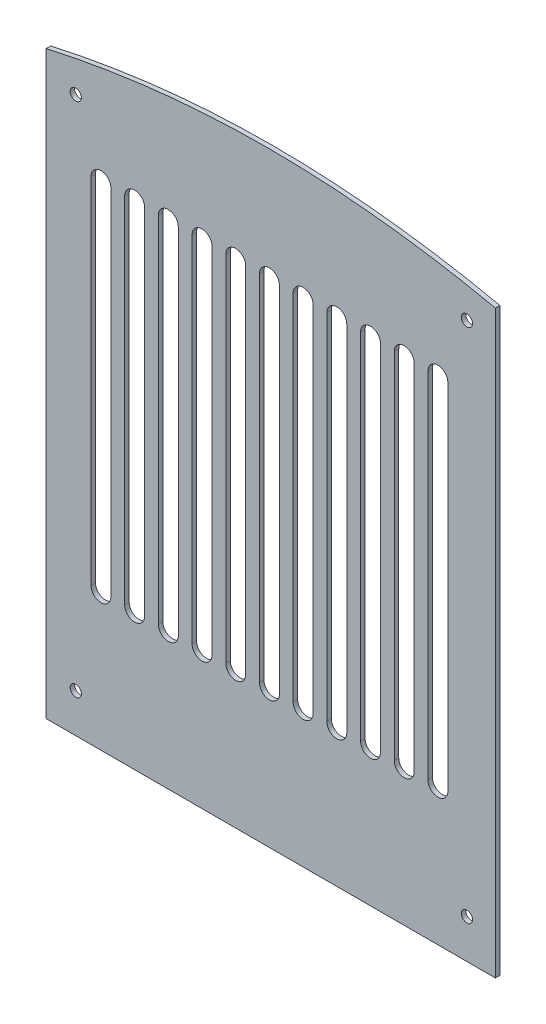
from build123d import *

# Parameters (mm, degrees)
SKETCH1_R           = 2.5
BOSS_EXTRUDE1_DEPTH = 2


with BuildPart() as part:
    # Sketch1 → Boss-Extrude1 (new body)
    with BuildSketch(Plane.XY):
        with BuildLine():
            Line((79.989677419, 0), (-120.010322581, 0))
            Line((-120.010322581, 0), (-120.010322581, 258.3))
            add(Edge.make_bspline(
                [(-120.010322581, 258.3), (-22.49451042, 280.450990468), (79.989677419, 258.3)],
                knots=[0, 0, 0, 1, 1, 1], degree=2))
            Line((79.989677419, 258.3), (79.989677419, 0))
        make_face()
        with Locations((-106.803669914, 247.177426871)):
            Circle(SKETCH1_R, mode=Mode.SUBTRACT)
        with Locations((67.322454172, 247.177426871)):
            Circle(SKETCH1_R, mode=Mode.SUBTRACT)
        with Locations((67.322454172, 17.342199543)):
            Circle(SKETCH1_R, mode=Mode.SUBTRACT)
        with Locations((-106.803669914, 17.342199543)):
            Circle(SKETCH1_R, mode=Mode.SUBTRACT)
        with BuildLine():
            Line((-91.175010368, 219.031134186), (-91.175010368, 61.345209981))
            ThreePointArc((-91.175010368, 61.345209981), (-95.604390261, 56.915830088), (-100.033770154, 61.345209981))
            Line((-100.033770154, 61.345209981), (-100.033770154, 219.031134186))
            ThreePointArc((-100.033770154, 219.031134186), (-95.604390261, 223.460514079), (-91.175010368, 219.031134186))
        make_face(mode=Mode.SUBTRACT)
        with BuildLine():
            Line((-76.175010368, 219.031134186), (-76.175010368, 61.345209981))
            ThreePointArc((-76.175010368, 61.345209981), (-80.604390261, 56.915830088), (-85.033770154, 61.345209981))
            Line((-85.033770154, 61.345209981), (-85.033770154, 219.031134186))
            ThreePointArc((-85.033770154, 219.031134186), (-80.604390261, 223.460514079), (-76.175010368, 219.031134186))
        make_face(mode=Mode.SUBTRACT)
        with BuildLine():
            Line((-61.175010368, 219.031134186), (-61.175010368, 61.345209981))
            ThreePointArc((-61.175010368, 61.345209981), (-65.604390261, 56.915830088), (-70.033770154, 61.345209981))
            Line((-70.033770154, 61.345209981), (-70.033770154, 219.031134186))
            ThreePointArc((-70.033770154, 219.031134186), (-65.604390261, 223.460514079), (-61.175010368, 219.031134186))
        make_face(mode=Mode.SUBTRACT)
        with BuildLine():
            Line((-46.175010368, 219.031134186), (-46.175010368, 61.345209981))
            ThreePointArc((-46.175010368, 61.345209981), (-50.604390261, 56.915830088), (-55.033770154, 61.345209981))
            Line((-55.033770154, 61.345209981), (-55.033770154, 219.031134186))
            ThreePointArc((-55.033770154, 219.031134186), (-50.604390261, 223.460514079), (-46.175010368, 219.031134186))
        make_face(mode=Mode.SUBTRACT)
        with BuildLine():
            Line((-31.175010368, 219.031134186), (-31.175010368, 61.345209981))
            ThreePointArc((-31.175010368, 61.345209981), (-35.604390261, 56.915830088), (-40.033770154, 61.345209981))
            Line((-40.033770154, 61.345209981), (-40.033770154, 219.031134186))
            ThreePointArc((-40.033770154, 219.031134186), (-35.604390261, 223.460514079), (-31.175010368, 219.031134186))
        make_face(mode=Mode.SUBTRACT)
        with BuildLine():
            Line((-16.175010368, 219.031134186), (-16.175010368, 61.345209981))
            ThreePointArc((-16.175010368, 61.345209981), (-20.604390261, 56.915830088), (-25.033770154, 61.345209981))
            Line((-25.033770154, 61.345209981), (-25.033770154, 219.031134186))
            ThreePointArc((-25.033770154, 219.031134186), (-20.604390261, 223.460514079), (-16.175010368, 219.031134186))
        make_face(mode=Mode.SUBTRACT)
        with BuildLine():
            Line((-1.175010368, 219.031134186), (-1.175010368, 61.345209981))
            ThreePointArc((-1.175010368, 61.345209981), (-5.604390261, 56.915830088), (-10.033770154, 61.345209981))
            Line((-10.033770154, 61.345209981), (-10.033770154, 219.031134186))
            ThreePointArc((-10.033770154, 219.031134186), (-5.604390261, 223.460514079), (-1.175010368, 219.031134186))
        make_face(mode=Mode.SUBTRACT)
        with BuildLine():
            Line((13.824989632, 219.031134186), (13.824989632, 61.345209981))
            ThreePointArc((13.824989632, 61.345209981), (9.395609739, 56.915830088), (4.966229846, 61.345209981))
            Line((4.966229846, 61.345209981), (4.966229846, 219.031134186))
            ThreePointArc((4.966229846, 219.031134186), (9.395609739, 223.460514079), (13.824989632, 219.031134186))
        make_face(mode=Mode.SUBTRACT)
        with BuildLine():
            Line((28.824989632, 219.031134186), (28.824989632, 61.345209981))
            ThreePointArc((28.824989632, 61.345209981), (24.395609739, 56.915830088), (19.966229846, 61.345209981))
            Line((19.966229846, 61.345209981), (19.966229846, 219.031134186))
            ThreePointArc((19.966229846, 219.031134186), (24.395609739, 223.460514079), (28.824989632, 219.031134186))
        make_face(mode=Mode.SUBTRACT)
        with BuildLine():
            Line((43.824989632, 219.031134186), (43.824989632, 61.345209981))
            ThreePointArc((43.824989632, 61.345209981), (39.395609739, 56.915830088), (34.966229846, 61.345209981))
            Line((34.966229846, 61.345209981), (34.966229846, 219.031134186))
            ThreePointArc((34.966229846, 219.031134186), (39.395609739, 223.460514079), (43.824989632, 219.031134186))
        make_face(mode=Mode.SUBTRACT)
        with BuildLine():
            Line((58.824989632, 219.031134186), (58.824989632, 61.345209981))
            ThreePointArc((58.824989632, 61.345209981), (54.395609739, 56.915830088), (49.966229846, 61.345209981))
            Line((49.966229846, 61.345209981), (49.966229846, 219.031134186))
            ThreePointArc((49.966229846, 219.031134186), (54.395609739, 223.460514079), (58.824989632, 219.031134186))
        make_face(mode=Mode.SUBTRACT)
    extrude(amount=BOSS_EXTRUDE1_DEPTH)


solid = part.part
